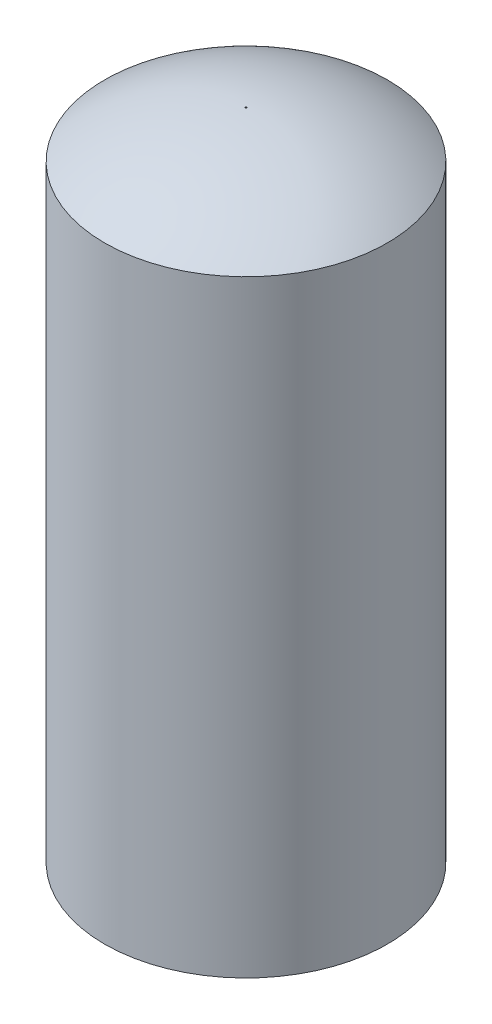
from build123d import *


with BuildPart() as part:
    # Эскиз1 → Повернуть-Тонкостенный3 (revolve)
    with BuildSketch(Plane(origin=(0, 0, 0), x_dir=(0, 0, -1), z_dir=(1, 0, 0))):
        with BuildLine():
            ThreePointArc((1, 0), (105.7166575, 16.855175566), (200, 65.438368426))
            Line((200, 65.438368426), (200, 934.561631574))
            ThreePointArc((200, 934.561631574), (105.7166575, 983.144824434), (1, 1000))
            Line((1, 1000), (1.004453384, 1002.999996695))
            ThreePointArc((1.004453384, 1002.999996695), (107.375751508, 985.756396385), (203, 936.075435077))
            Line((203, 936.075435077), (203, 63.924564923))
            ThreePointArc((203, 63.924564923), (107.375751508, 14.243603615), (1.004453384, -2.999996695))
            Line((1.004453384, -2.999996695), (1, 0))
        make_face()
    revolve(axis=Axis((0, -42.73513709, 0), (0, 1, 0)))


solid = part.part
